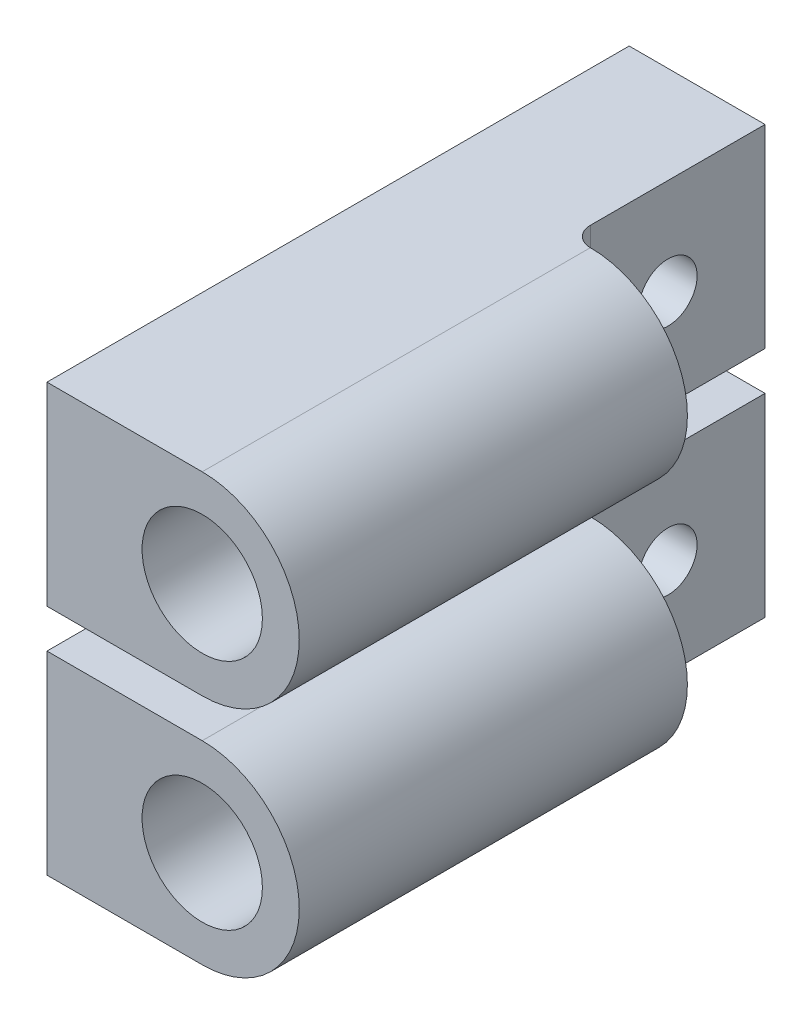
from build123d import *

# Parameters (mm, degrees)
MAIN_DEPTH                     = 30
SKETCH2_R                      = 3.1
SHAFTHOLE_DEPTH                = 16
SKETCH3_W                      = 10
SKETCH3_H                      = 10
MAKERBEAMRECTANGULARHOLE_DEPTH = 7
SKETCH4_R                      = 1.5
MAKERBEAMHOLE_DEPTH            = 8
FILLET1_R                      = 1
LPATTERN1_COUNT                = 2
LPATTERN1_PITCH                = 12


with BuildPart() as part:
    # Sketch1 → Main (new body)
    with BuildSketch(Plane.XY):
        with BuildLine():
            Line((-8, 5), (-8, -5))
            Line((-8, -5), (0, -5))
            ThreePointArc((0, -5), (5, 0), (0, 5))
            Line((0, 5), (-8, 5))
        make_face()
    extrude(amount=MAIN_DEPTH)

    # Sketch2 → ShaftHole (cut)
    with BuildSketch(Plane.XY.offset(30)):
        Circle(SKETCH2_R)
    extrude(amount=-SHAFTHOLE_DEPTH, mode=Mode.SUBTRACT)

    # Sketch3 → MakerBeamRectangularHole (cut, through all)
    with BuildSketch(Plane(origin=(-1, 0, 0), x_dir=(0, 0, -1), z_dir=(1, 0, 0))):
        with Locations((-5, 0)):
            Rectangle(SKETCH3_W, SKETCH3_H)
    extrude(amount=MAKERBEAMRECTANGULARHOLE_DEPTH, mode=Mode.SUBTRACT)

    # Sketch4 → MakerBeamHole (cut, through all)
    with BuildSketch(Plane(origin=(-1, 0, 0), x_dir=(0, 0, -1), z_dir=(1, 0, 0))):
        with Locations((-5, 0)):
            Circle(SKETCH4_R)
    extrude(amount=-MAKERBEAMHOLE_DEPTH, mode=Mode.SUBTRACT)

    # Fillet1
    fillet1_edges = [part.edges().sort_by_distance(p)[0] for p in [
        (-1, 0, 10),
    ]]
    fillet(fillet1_edges, radius=FILLET1_R)


with BuildPart() as lpattern1_1:
    # LPattern1: pattern copy
    add(part.part.moved(Location(Vector(0, 1, 0) * (1 * LPATTERN1_PITCH))))


solid = Compound([part.part, lpattern1_1.part])
